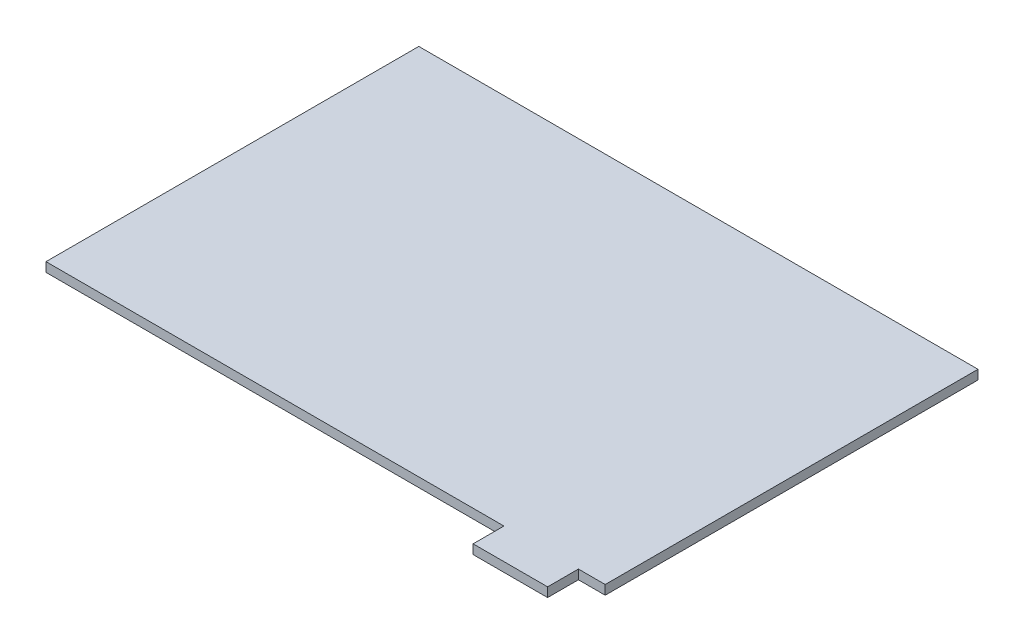
from build123d import *

# Parameters (mm, degrees)
BOSS_EXTRUDE1_DEPTH = 2.54


with BuildPart() as part:
    # Sketch1 → Boss-Extrude1 (new body)
    with BuildSketch(Plane(origin=(0, 0, 0), x_dir=(1, 0, 0), z_dir=(0, 1, 0))):
        Polygon((48.6, -50.8), (48.6, -59.2), (68.9, -59.2), (68.9, -50.8), (76.2, -50.8), (76.2, 50.8), (-76.2, 50.8), (-76.2, -50.8), align=None)
    extrude(amount=BOSS_EXTRUDE1_DEPTH)


solid = part.part
